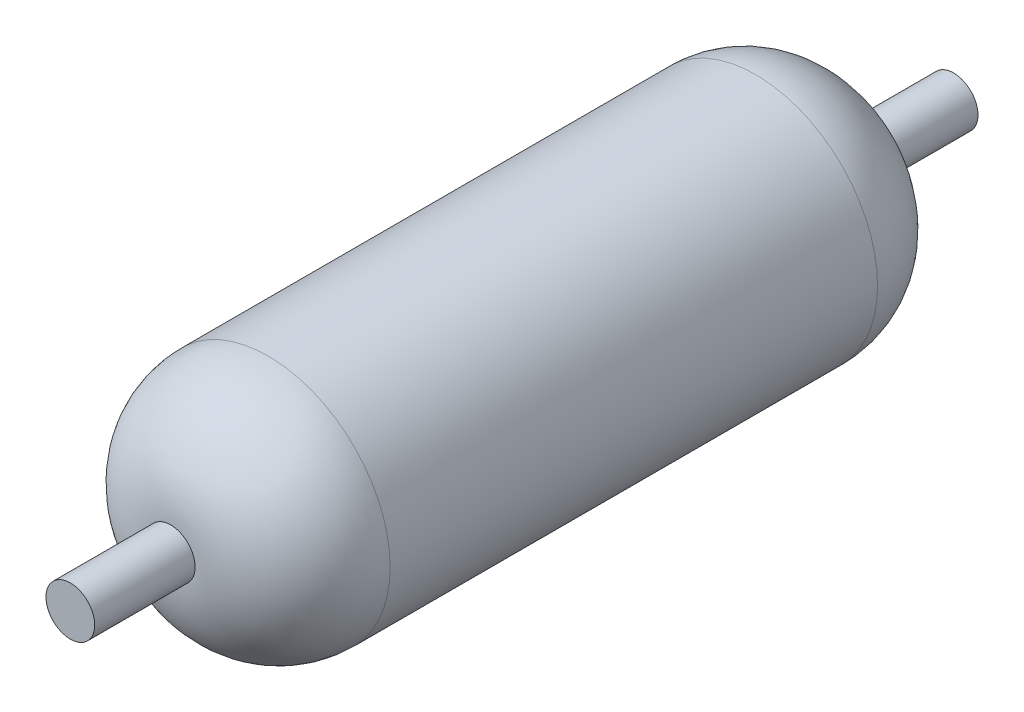
from build123d import *

# Parameters (mm, degrees)
SKETCH1_R           = 1.25
BOSS_EXTRUDE1_DEPTH = 3.5
FILLET1_R           = 1
SKETCH2_R           = 0.25
BOSS_EXTRUDE2_DEPTH = 4.53


with BuildPart() as part:
    # Sketch1 → Boss-Extrude1 (new body, symmetric)
    with BuildSketch(Plane.XY):
        Circle(SKETCH1_R)
    extrude(amount=BOSS_EXTRUDE1_DEPTH, both=True)

    # Fillet1
    fillet1_edges = [part.edges().sort_by_distance(p)[0] for p in [
        (-1.25, 0, -3.5),
        (-1.25, 0, 3.5),
    ]]
    fillet(fillet1_edges, radius=FILLET1_R)


with BuildPart() as body_2:
    # Sketch2 → Boss-Extrude2 (new body, symmetric)
    with BuildSketch(Plane.XY):
        Circle(SKETCH2_R)
    extrude(amount=BOSS_EXTRUDE2_DEPTH, both=True)


solid = Compound([part.part, body_2.part])
